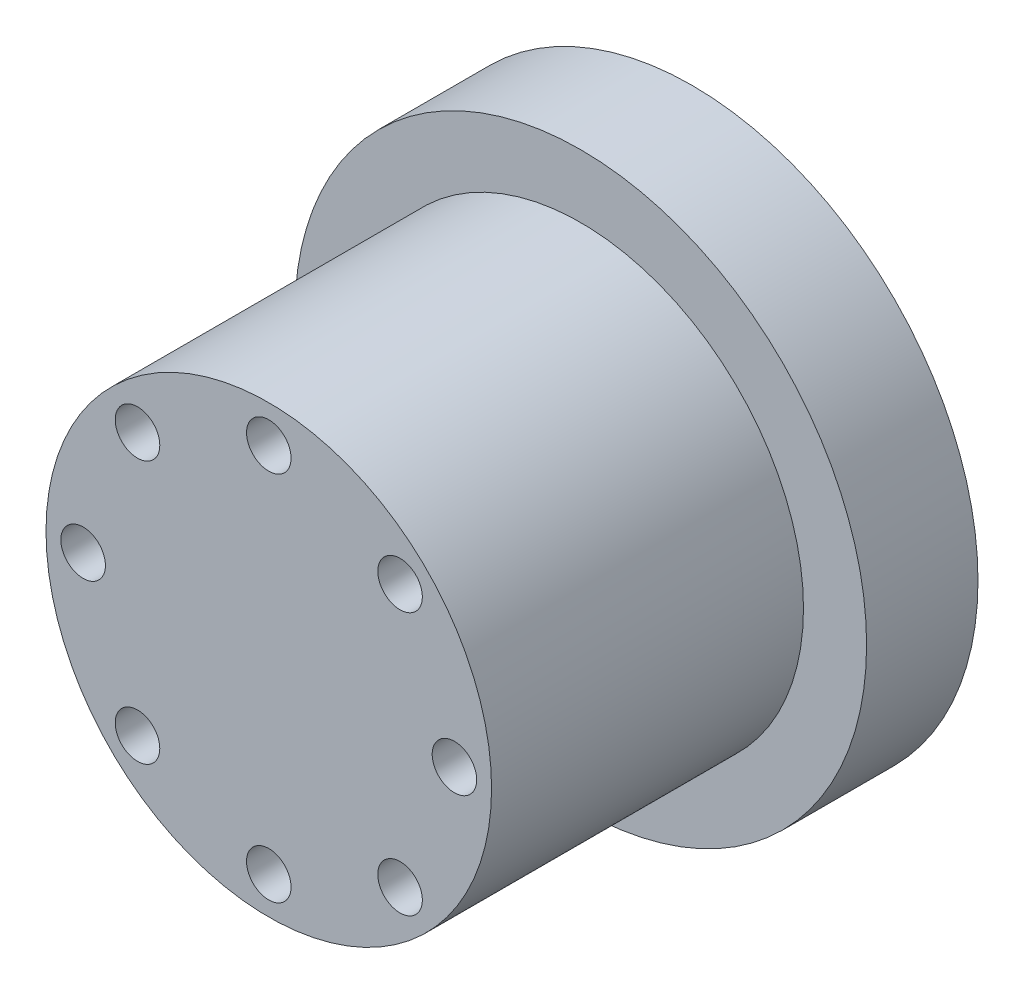
from build123d import *

# Parameters (mm, degrees)
SKETCH2_R           = 30
BOSS_EXTRUDE1_DEPTH = 42
SKETCH2_4_R         = 38.5
BOSS_EXTRUDE2_DEPTH = 15
SKETCH3_R           = 3
CUT_EXTRUDE1_DEPTH  = 10
CUT_EXTRUDE2_START  = -10
SKETCH4_R           = 3
CUT_EXTRUDE2_DEPTH  = 10


with BuildPart() as part:
    # Sketch2 → Boss-Extrude1 (new body)
    with BuildSketch(Plane.XY):
        Circle(SKETCH2_R)
    extrude(amount=BOSS_EXTRUDE1_DEPTH)

    # Sketch2_4 → Boss-Extrude2 (add)
    with BuildSketch(Plane.XY):
        Circle(SKETCH2_4_R)
    extrude(amount=-BOSS_EXTRUDE2_DEPTH)

    # Sketch3 → Cut-Extrude1 (cut)
    with BuildSketch(Plane(origin=(0, 0, -15), x_dir=(-1, 0, 0), z_dir=(0, 0, -1))):
        with Locations((0, 25)):
            Circle(SKETCH3_R)
        with Locations((25, 0)):
            Circle(SKETCH3_R)
        with Locations((0, -25)):
            Circle(SKETCH3_R)
        with Locations((-25, 0)):
            Circle(SKETCH3_R)
    extrude(amount=-CUT_EXTRUDE1_DEPTH, mode=Mode.SUBTRACT)

    # Sketch4 → Cut-Extrude2 (cut)
    with BuildSketch(Plane.XY.offset(42).offset(CUT_EXTRUDE2_START)):
        with Locations((0, 25)):
            Circle(SKETCH4_R)
        with Locations((17.67766953, 17.67766953)):
            Circle(SKETCH4_R)
        with Locations((25, 0)):
            Circle(SKETCH4_R)
        with Locations((17.67766953, -17.67766953)):
            Circle(SKETCH4_R)
        with Locations((0, -25)):
            Circle(SKETCH4_R)
        with Locations((-17.67766953, -17.67766953)):
            Circle(SKETCH4_R)
        with Locations((-25, 0)):
            Circle(SKETCH4_R)
        with Locations((-17.67766953, 17.67766953)):
            Circle(SKETCH4_R)
    extrude(amount=CUT_EXTRUDE2_DEPTH, mode=Mode.SUBTRACT)


solid = part.part
